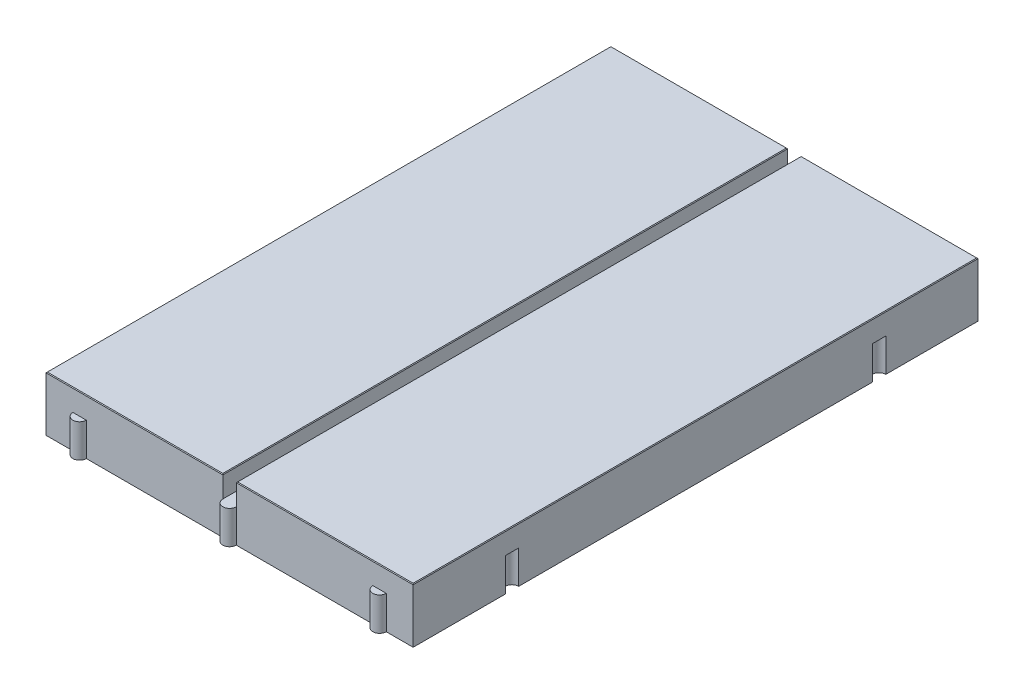
from build123d import *

# Parameters (mm, degrees)
SKETCH1_W           = 54.6
SKETCH1_H           = 84
BOSS_EXTRUDE1_DEPTH = 8.15
SKETCH2_W           = 2
SKETCH2_H           = 84
CUT_EXTRUDE1_DEPTH  = 3.2
CHAMFER1_SIZE       = 0.1
BOSS_EXTRUDE2_DEPTH = 4.95
CUT_EXTRUDE4_DEPTH  = 4.95


with BuildPart() as part:
    # Sketch1 → Boss-Extrude1 (new body)
    with BuildSketch(Plane(origin=(0, 0, 0), x_dir=(1, 0, 0), z_dir=(0, 1, 0))):
        Rectangle(SKETCH1_W, SKETCH1_H)
    extrude(amount=BOSS_EXTRUDE1_DEPTH)

    # Sketch2 → Cut-Extrude1 (cut)
    with BuildSketch(Plane(origin=(0, 8.15, 0), x_dir=(1, 0, 0), z_dir=(0, 1, 0))):
        Rectangle(SKETCH2_W, SKETCH2_H)
    extrude(amount=-CUT_EXTRUDE1_DEPTH, mode=Mode.SUBTRACT)

    # Chamfer1
    chamfer1_edges = [part.edges().sort_by_distance(p)[0] for p in [
        (-27.3, 8.15, 0),
        (-14.15, 8.15, 42),
        (-14.15, 8.15, -42),
        (14.15, 8.15, 42),
        (1, 8.15, 0),
        (-1, 8.15, 0),
        (27.3, 8.15, 0),
        (14.15, 8.15, -42),
    ]]
    chamfer(chamfer1_edges, length=CHAMFER1_SIZE)

    # Sketch6 → Boss-Extrude2 (add)
    with BuildSketch(Plane(origin=(0, 0, 0), x_dir=(1, 0, 0), z_dir=(0, 1, 0))):
        with BuildLine():
            Line((-27.3, 26.3), (-27.3, 28.3))
            ThreePointArc((-27.3, 28.3), (-28.3, 27.3), (-27.3, 26.3))
        make_face()
        with BuildLine():
            Line((-21.3, -42), (-23.3, -42))
            ThreePointArc((-23.3, -42), (-22.3, -43), (-21.3, -42))
        make_face()
        with BuildLine():
            Line((-27.3, -28.3), (-27.3, -26.3))
            ThreePointArc((-27.3, -26.3), (-28.3, -27.3), (-27.3, -28.3))
        make_face()
        with BuildLine():
            Line((1, -42), (-1, -42))
            ThreePointArc((-1, -42), (0, -43), (1, -42))
        make_face()
        with BuildLine():
            Line((23.3, -42), (21.3, -42))
            ThreePointArc((21.3, -42), (22.3, -43), (23.3, -42))
        make_face()
    extrude(amount=BOSS_EXTRUDE2_DEPTH)

    # Sketch13 → Cut-Extrude4 (cut)
    with BuildSketch(Plane(origin=(0, 0, 0), x_dir=(1, 0, 0), z_dir=(0, 1, 0))):
        with BuildLine():
            Line((27.3, 28.3), (27.3, 26.3))
            ThreePointArc((27.3, 26.3), (26.3, 27.3), (27.3, 28.3))
        make_face()
        with BuildLine():
            Line((-23.3, 42), (-21.3, 42))
            ThreePointArc((-21.3, 42), (-22.3, 41), (-23.3, 42))
        make_face()
        with BuildLine():
            Line((27.3, -26.3), (27.3, -28.3))
            ThreePointArc((27.3, -28.3), (26.3, -27.3), (27.3, -26.3))
        make_face()
        with BuildLine():
            Line((-1, 42), (1, 42))
            ThreePointArc((1, 42), (0, 41), (-1, 42))
        make_face()
        with BuildLine():
            Line((21.3, 42), (23.3, 42))
            ThreePointArc((23.3, 42), (22.3, 41), (21.3, 42))
        make_face()
    extrude(amount=CUT_EXTRUDE4_DEPTH, mode=Mode.SUBTRACT)


solid = part.part
